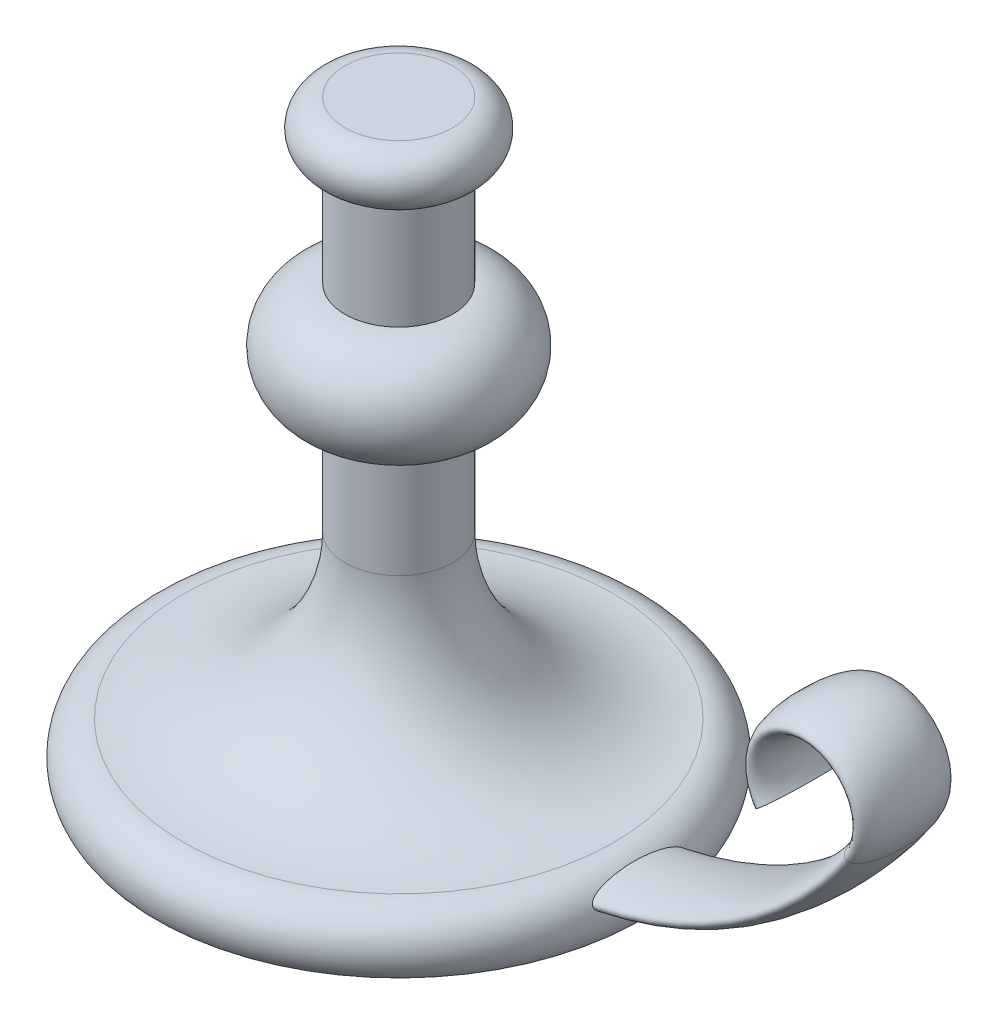
from build123d import *

# Parameters (mm, degrees)
CROQUIS3_RX = 17.5
CROQUIS3_RY = 5


with BuildPart() as part:
    # Croquis1 → Revolución1 (revolve)
    with BuildSketch(Plane.XY):
        with BuildLine():
            Line((0, 0), (90, 0))
            ThreePointArc((90, 0), (91.180339887, 13.090169944), (80, 20))
            ThreePointArc((80, 20), (37.573593129, 37.573593129), (20, 80))
            Line((20, 80), (20, 120))
            ThreePointArc((20, 120), (40, 140), (20, 160))
            Line((20, 160), (20, 200))
            ThreePointArc((20, 200), (30, 210), (20, 220))
            Line((20, 220), (0, 220))
            Line((0, 220), (0, 0))
        make_face()
    revolve(axis=Axis((0, 0, 0), (0, 1, 0)))

    # Barrer1: sweep along a path in Croquis2
    with BuildLine(Plane.XY) as barrer1_path:
        Line((0, 10), (60, 10))
        ThreePointArc((60, 10), (129.821200219, 27.240819526), (183.592070943, 75))
        ThreePointArc((183.592070943, 75), (167.113128151, 106.333333333), (150.634185358, 75))
    # Croquis3 → Barrer1 (sweep)
    with BuildSketch(Plane(origin=(0, 0, 0), x_dir=(0, 0, -1), z_dir=(1, 0, 0))):
        with Locations((0, 10)):
            Ellipse(CROQUIS3_RX, CROQUIS3_RY)
    sweep(path=barrer1_path.line)


solid = part.part
